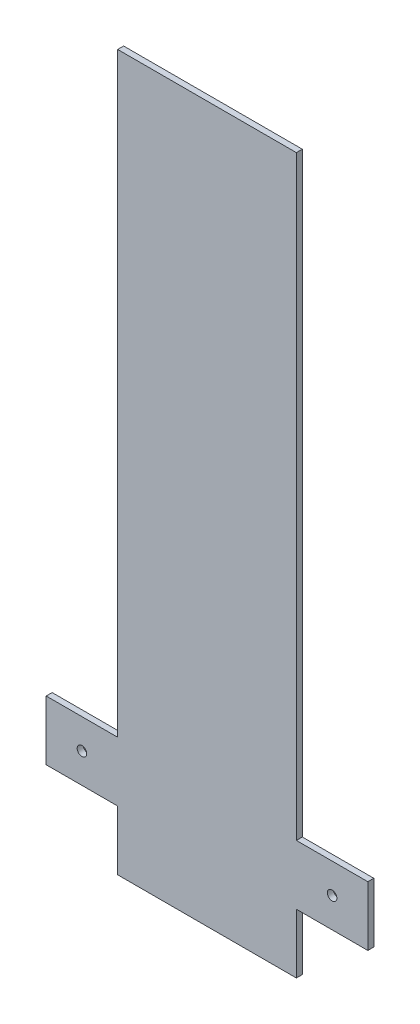
from build123d import *

# Parameters (mm, degrees)
SKETCH2_R           = 4
BOSS_EXTRUDE1_DEPTH = 5


with BuildPart() as part:
    # Sketch2 → Boss-Extrude1 (new body)
    with BuildSketch(Plane.XY):
        Polygon((75, 300), (75, -200), (135, -200), (135, -250), (75, -250), (75, -300), (-75, -300), (-75, -250), (-135, -250), (-135, -200), (-75, -200), (-75, 300), align=None)
        with Locations((-105, -225)):
            Circle(SKETCH2_R, mode=Mode.SUBTRACT)
        with Locations((105, -225)):
            Circle(SKETCH2_R, mode=Mode.SUBTRACT)
    extrude(amount=BOSS_EXTRUDE1_DEPTH)


solid = part.part
